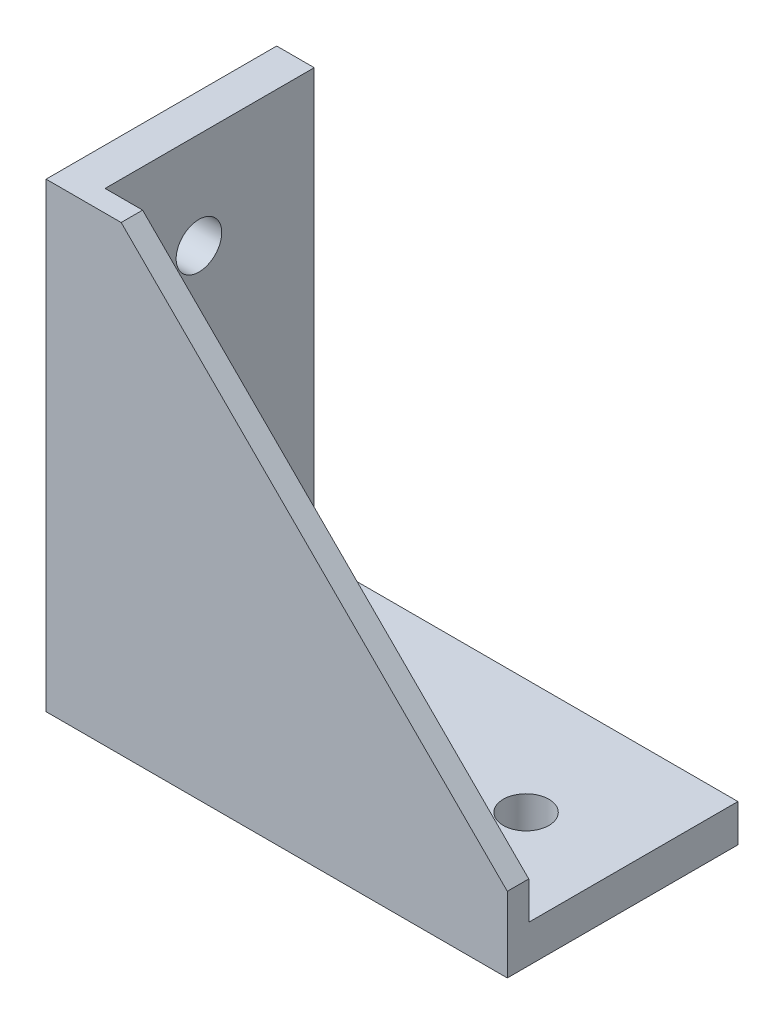
from build123d import *

# Parameters (mm, degrees)
EXTRUDE_1_DEPTH     = 21.5
EXTRUDE_2_DEPTH     = 4
SKETCH_3_R          = 4.25
CUT_EXTRUDE_1_DEPTH = 8
SKETCH_4_W          = 3
SKETCH_4_H          = 10
EXTRUDE_3_DEPTH     = 3


with BuildPart() as part:
    # Эскиз1 → Бобышка-Вытянуть1 (new body, symmetric)
    with BuildSketch(Plane.XY):
        Polygon((0, 86), (0, 0), (86, 0), (86, 7), (7, 7), (7, 86), align=None)
    extrude(amount=EXTRUDE_1_DEPTH, both=True)

    # Эскиз2 → Бобышка-Вытянуть2 (add)
    with BuildSketch(Plane.XY.offset(21.5)):
        Polygon((86, 7), (7, 7), (7, 86), (14, 86), (86, 14), align=None)
    extrude(amount=-EXTRUDE_2_DEPTH)

    # Эскиз3 → Вырез-Вытянуть1 (cut, through all)
    with BuildSketch(Plane(origin=(0, 7, 0), x_dir=(1, 0, 0), z_dir=(0, 1, 0))):
        with Locations(Location((68, 0, 0), (0, 0, 270))):  # turned: the seam where the file's is
            Circle(SKETCH_3_R)
        with BuildLine():
            Line((20, 4.25), (46, 4.25))
            ThreePointArc((46, 4.25), (50.25, 0), (46, -4.25))
            Line((46, -4.25), (20, -4.25))
            ThreePointArc((20, -4.25), (15.75, 0), (20, 4.25))
        make_face()
    cut_extrude_1 = extrude(amount=-CUT_EXTRUDE_1_DEPTH, mode=Mode.SUBTRACT)

    # Эскиз4 → Бобышка-Вытянуть3 (add)
    with BuildSketch(Plane.XZ):
        with Locations((4.5, 0)):
            Rectangle(SKETCH_4_W, SKETCH_4_H)
        with Locations((81.5, 0)):
            Rectangle(SKETCH_4_W, SKETCH_4_H)
    extrude_3 = extrude(amount=EXTRUDE_3_DEPTH)

    # Зеркальное отражение3: Вырез-Вытянуть1, Бобышка-Вытянуть3 across plane
    add(cut_extrude_1.mirror(Plane(origin=(0, 0, 0), x_dir=(0, 0, 1), z_dir=(-0.707106781, 0.707106781, 0))), mode=Mode.SUBTRACT)
    add(extrude_3.mirror(Plane(origin=(0, 0, 0), x_dir=(0, 0, 1), z_dir=(-0.707106781, 0.707106781, 0))))


solid = part.part
